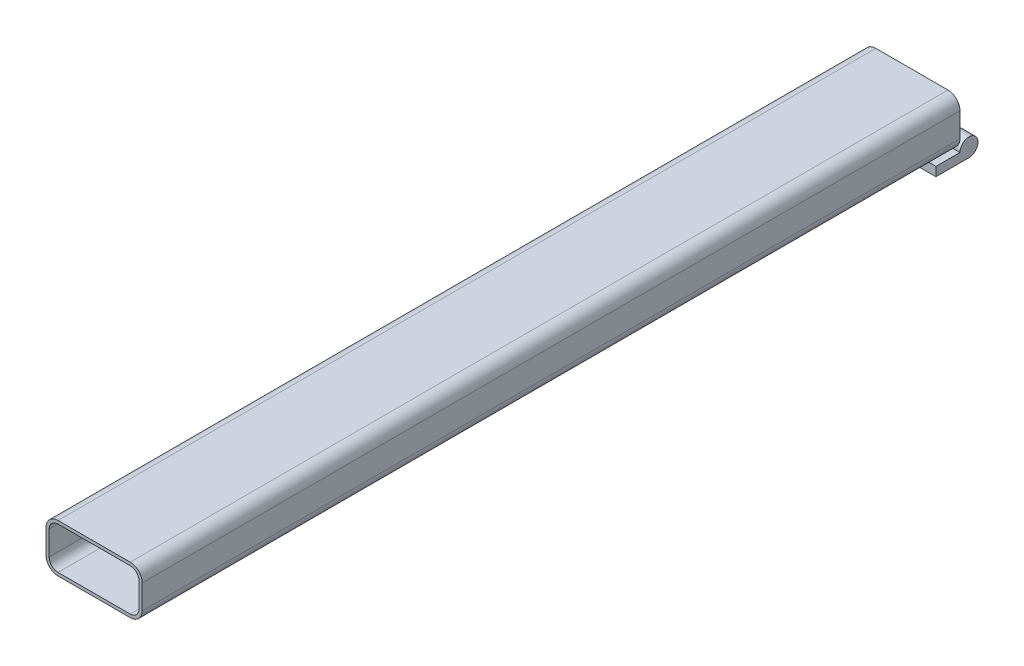
from build123d import *

# Parameters (mm, degrees)
BOSS_EXTRUDE1_DEPTH = 215.9
BOSS_EXTRUDE2_DEPTH = 50.8
SKETCH4_W           = 19.05
SKETCH4_H           = 9.525
CUT_EXTRUDE1_DEPTH  = 31.1625
SKETCH3_R           = 3.175
BOSS_EXTRUDE3_DEPTH = 19.05


with BuildPart() as part:
    # Sketch1 → Boss-Extrude1 (new body, symmetric)
    with BuildSketch(Plane.XY):
        with BuildLine():
            Line((-19.05, -12.7), (19.05, -12.7))
            ThreePointArc((19.05, -12.7), (23.540128061, -10.840128061), (25.4, -6.35))
            Line((25.4, -6.35), (25.4, 6.35))
            ThreePointArc((25.4, 6.35), (23.540128061, 10.840128061), (19.05, 12.7))
            Line((19.05, 12.7), (-19.05, 12.7))
            ThreePointArc((-19.05, 12.7), (-23.540128061, 10.840128061), (-25.4, 6.35))
            Line((-25.4, 6.35), (-25.4, -6.35))
            ThreePointArc((-25.4, -6.35), (-23.540128061, -10.840128061), (-19.05, -12.7))
        make_face()
        with BuildLine():
            Line((-19.05, 11.049), (19.05, 11.049))
            ThreePointArc((19.05, 11.049), (22.372694765, 9.672694765), (23.749, 6.35))
            Line((23.749, 6.35), (23.749, -6.35))
            ThreePointArc((23.749, -6.35), (22.372694765, -9.672694765), (19.05, -11.049))
            Line((19.05, -11.049), (-19.05, -11.049))
            ThreePointArc((-19.05, -11.049), (-22.372694765, -9.672694765), (-23.749, -6.35))
            Line((-23.749, -6.35), (-23.749, 6.35))
            ThreePointArc((-23.749, 6.35), (-22.372694765, 9.672694765), (-19.05, 11.049))
        make_face(mode=Mode.SUBTRACT)
    extrude(amount=BOSS_EXTRUDE1_DEPTH, both=True)

    # Sketch2 → Boss-Extrude2 (add, through all)
    with BuildSketch(Plane(origin=(25.4, 0, 0), x_dir=(0, 0, -1), z_dir=(1, 0, 0))):
        with BuildLine():
            Line((203.2, -12.7), (203.2, -17.4625))
            Line((203.2, -17.4625), (220.6625, -17.4625))
            ThreePointArc((220.6625, -17.4625), (224.030096045, -9.332403955), (215.9, -12.7))
            Line((215.9, -12.7), (203.2, -12.7))
        make_face()
    extrude(amount=-BOSS_EXTRUDE2_DEPTH)

    # Sketch4 → Cut-Extrude1 (cut, through all)
    with BuildSketch(Plane.XZ.offset(17.4625)):
        with Locations((0, -220.6625)):
            Rectangle(SKETCH4_W, SKETCH4_H)
    extrude(amount=-CUT_EXTRUDE1_DEPTH, mode=Mode.SUBTRACT)

    # Sketch3 → Boss-Extrude3 (add, symmetric)
    with BuildSketch(Plane(origin=(0, 0, 0), x_dir=(0, 0, -1), z_dir=(1, 0, 0))):
        with Locations((220.6625, -12.7)):
            Circle(SKETCH3_R)
    extrude(amount=BOSS_EXTRUDE3_DEPTH, both=True)


solid = part.part
